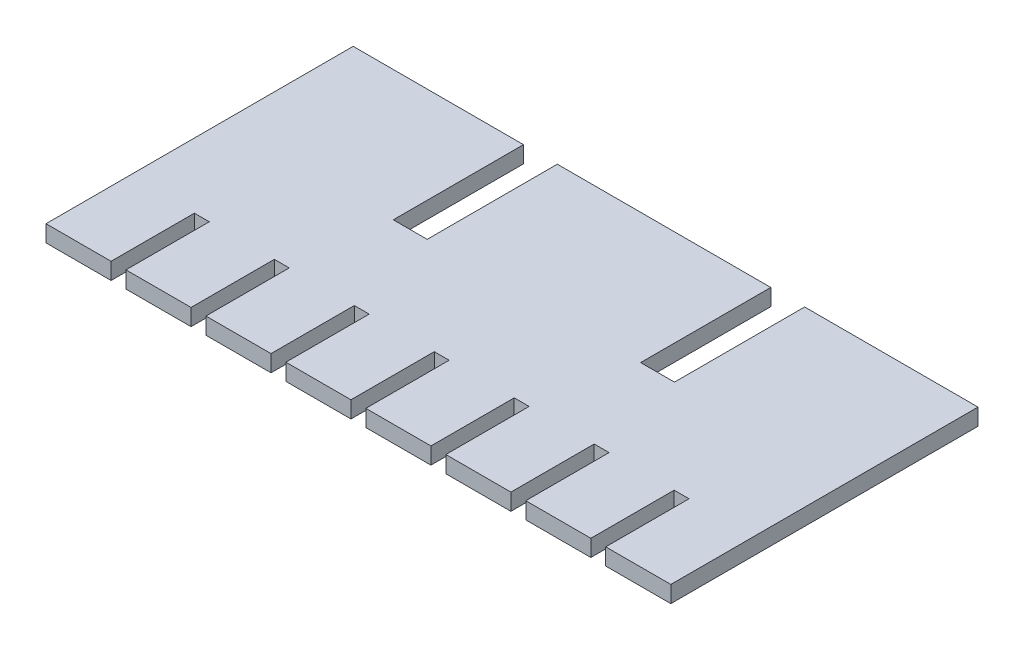
from build123d import *

# Parameters (mm, degrees)
BOSS_EXTRUDE1_DEPTH = 1.6


with BuildPart() as part:
    # Sketch1 → Boss-Extrude1 (new body)
    with BuildSketch(Plane(origin=(0, 0, 0), x_dir=(1, 0, 0), z_dir=(0, 1, 0))):
        Polygon((0, 0), (0, -29.5), (6.25, -29.5), (6.25, -21.5), (7.679, -21.5), (7.679, -29.5), (13.929, -29.5), (13.929, -21.5), (15.358, -21.5), (15.358, -29.5), (21.608, -29.5), (21.608, -21.5), (23.037, -21.5), (23.037, -29.5), (29.287, -29.5), (29.287, -21.5), (30.716, -21.5), (30.716, -29.5), (36.966, -29.5), (36.966, -21.5), (38.395, -21.5), (38.395, -29.5), (44.645, -29.5), (44.645, -21.5), (46.074, -21.5), (46.074, -29.5), (52.324, -29.5), (52.324, -21.5), (53.753, -21.5), (53.753, -29.5), (60.003, -29.5), (60.003, 0), (43.353, 0), (43.353, -12.5), (40.103, -12.5), (40.103, 0), (19.603, 0), (19.603, -12.5), (16.353, -12.5), (16.353, 0), align=None)
    extrude(amount=BOSS_EXTRUDE1_DEPTH)


solid = part.part
